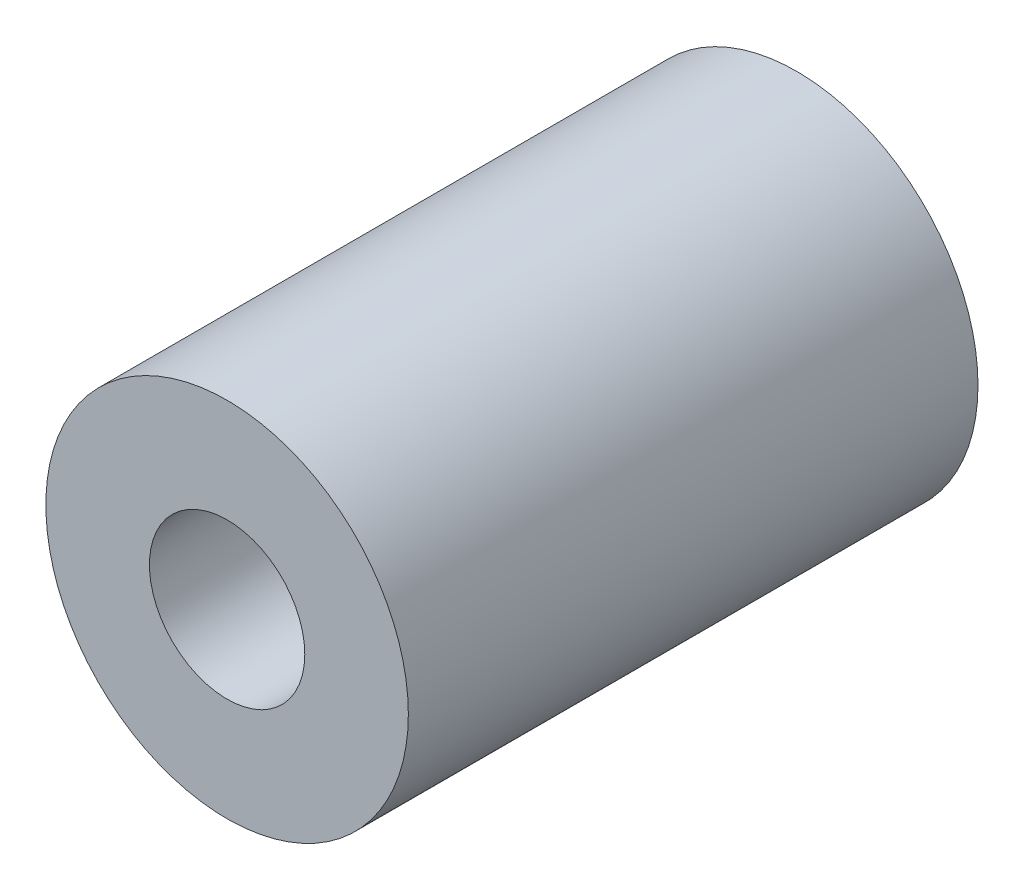
from build123d import *

# Parameters (mm, degrees)
SKETCH_1_R          = 7
EXTRUDE_1_DEPTH     = 22
SKETCH_2_R          = 3
CUT_EXTRUDE_1_DEPTH = 23


with BuildPart() as part:
    # 草图1 → 凸台-拉伸1 (new body)
    with BuildSketch(Plane.XY):
        Circle(SKETCH_1_R)
    extrude(amount=EXTRUDE_1_DEPTH)

    # 草图2 → 切除-拉伸1 (cut, through all)
    with BuildSketch(Plane.XY.offset(22)):
        Circle(SKETCH_2_R)
    extrude(amount=-CUT_EXTRUDE_1_DEPTH, mode=Mode.SUBTRACT)


solid = part.part
